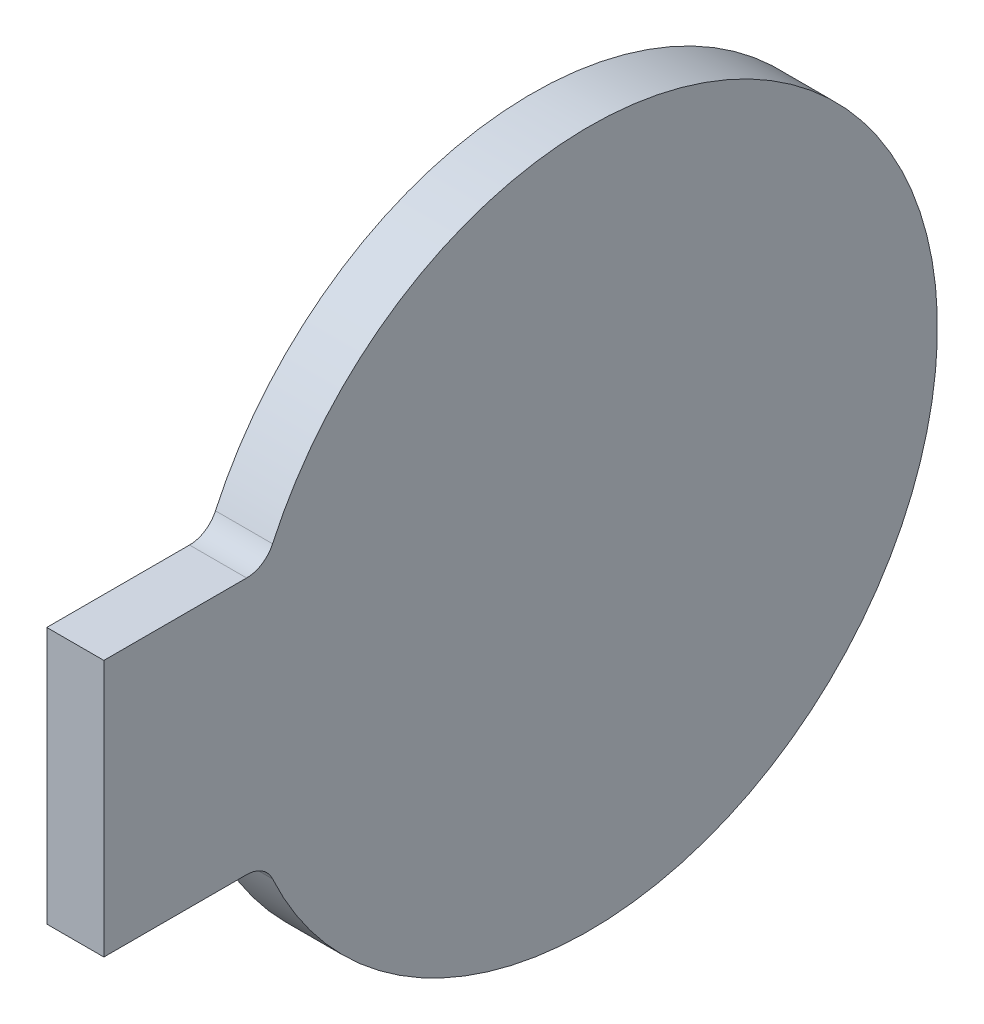
from build123d import *

# Parameters (mm, degrees)
SKETCH_1_W      = 2
SKETCH_1_H      = 12.2
SKETCH_2_W      = 2
SKETCH_2_H      = 9
EXTRUDE_1_DEPTH = 17
FILLET_3_R      = 1


with BuildPart() as part:
    # 草图1 → 旋转1 (revolve)
    with BuildSketch(Plane(origin=(0, 0, 0), x_dir=(1, 0, 0), z_dir=(0, 1, 0))):
        with Locations((-1, -6.1)):
            Rectangle(SKETCH_1_W, SKETCH_1_H)
    revolve(axis=Axis((0, 0, 0), (-1, 0, 0)))

    # 草图2 → 凸台-拉伸1 (add)
    with BuildSketch(Plane.XY):
        with Locations((-1, 0)):
            Rectangle(SKETCH_2_W, SKETCH_2_H)
    extrude(amount=EXTRUDE_1_DEPTH)

    # 圆角3
    fillet_3_edges = [part.edges().sort_by_distance(p)[0] for p in [
        (-1, -4.5, 11.339753084),
        (-1, 4.5, 11.339753084),
    ]]
    fillet(fillet_3_edges, radius=FILLET_3_R)


solid = part.part
